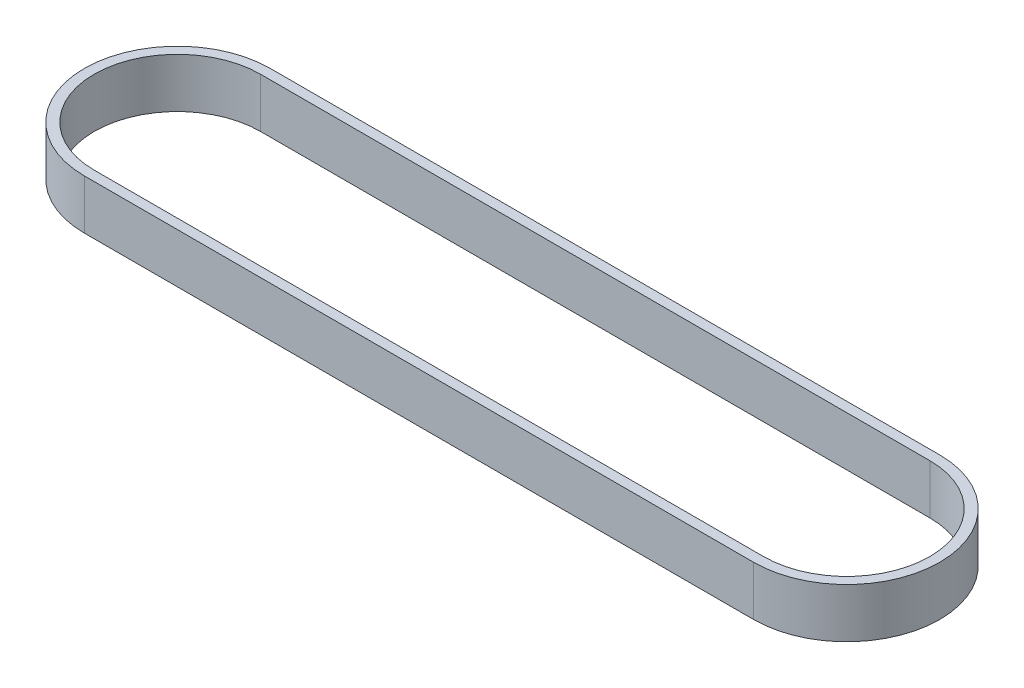
from build123d import *

# Parameters (mm, degrees)
EXTRUDE_1_DEPTH = 10


with BuildPart() as part:
    # 草图1 → 拉伸-薄壁1 (new body)
    with BuildSketch(Plane(origin=(0, 0, 0), x_dir=(1, 0, 0), z_dir=(0, 1, 0))):
        with BuildLine():
            Line((135, -18.76), (0, -18.76))
            ThreePointArc((0, -18.76), (-18.76, 0), (0, 18.76))
            Line((0, 18.76), (135, 18.76))
            ThreePointArc((135, 18.76), (153.76, 0), (135, -18.76))
        make_face()
        with BuildLine():
            Line((135, -16.76), (0, -16.76))
            ThreePointArc((0, -16.76), (-16.76, 0), (0, 16.76))
            Line((0, 16.76), (135, 16.76))
            ThreePointArc((135, 16.76), (151.76, 0), (135, -16.76))
        make_face(mode=Mode.SUBTRACT)
    extrude(amount=EXTRUDE_1_DEPTH)


solid = part.part
